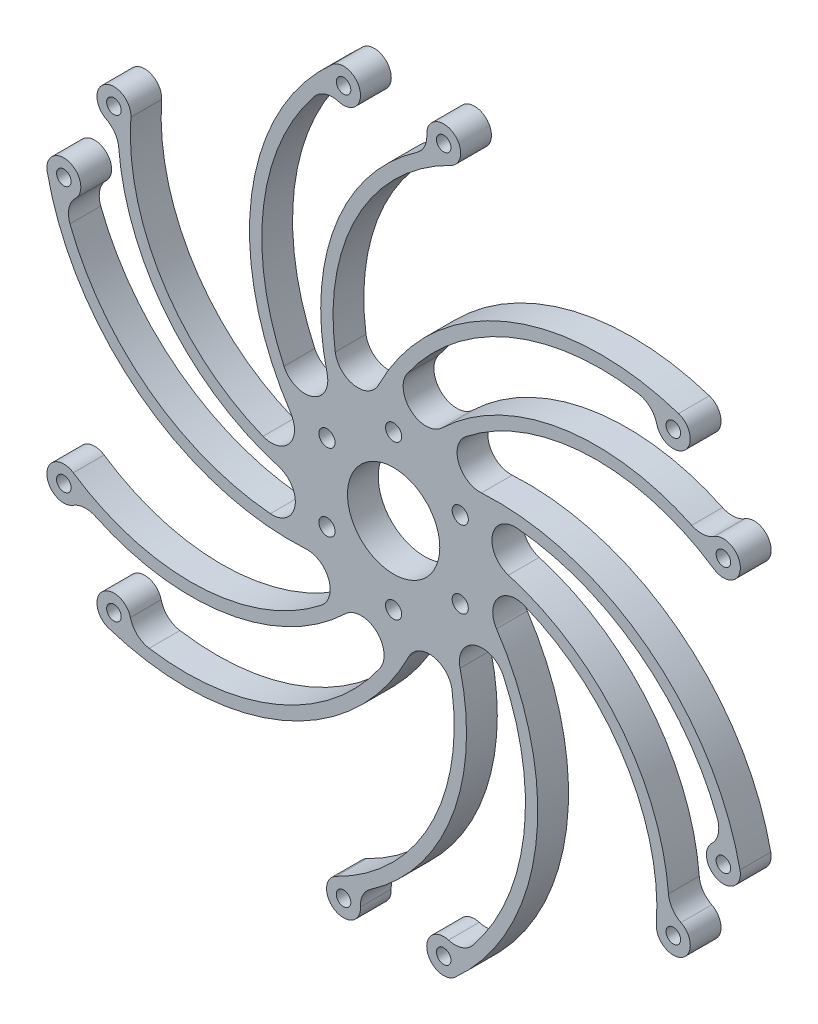
from build123d import *

# Parameters (mm, degrees)
SKETCH1_R                       = 31.75
SKETCH1_R_2                     = 14.2875
BOSS_EXTRUDE1_DEPTH             = 4.7625
BOSS_EXTRUDE2_REACH             = 47.153
SKETCH1_3_R                     = 2.25
BOSS_EXTRUDE2_DIRECTION_2_REACH = 47.153
SKETCH1_5_R                     = 2.5
CUT_EXTRUDE1_DEPTH              = 123.652767423
CIRPATTERN1_COUNT               = 6


with BuildPart() as part:
    # Sketch1 → Boss-Extrude1 (new, symmetric)
    with BuildSketch(Plane.XY):
        Circle(SKETCH1_R)
        Circle(SKETCH1_R_2, mode=Mode.SUBTRACT)
    extrude(amount=BOSS_EXTRUDE1_DEPTH, both=True)

    # Boss-Extrude2: up to this face of the body (flat: up to its plane)
    boss_extrude2_end = Plane(part.part.faces().sort_by_distance((-30.851974388, 0, 4.7625))[0])
    # Sketch1_3 → Boss-Extrude2 (add, up to the picked face)
    with BuildSketch(Plane.XY, mode=Mode.PRIVATE) as boss_extrude2_sk1:
        with BuildLine():
            ThreePointArc((-16.975976856, 103.864226407), (-10.380000805, 110.063559945), (-19.004913728, 112.811197739))
            ThreePointArc((-19.004913728, 112.811197739), (-43.981596647, 65.290659685), (-31.853644116, 12.993919882))
            ThreePointArc((-31.853644116, 12.993919882), (-30.783267014, 10.305575859), (-30.872393941, 7.4133523))
            ThreePointArc((-30.872393941, 7.4133523), (-27.701380897, 15.51438031), (-22.45064034, 22.450640265))
            ThreePointArc((-22.45064034, 22.450640265), (-28.712576811, 20.475279906), (-33.923533352, 24.470255355))
            ThreePointArc((-33.923533352, 24.470255355), (-40.260809011, 64.341772494), (-24.504598742, 101.512201327))
            ThreePointArc((-24.504598742, 101.512201327), (-21.096215477, 103.827506526), (-16.975976856, 103.864226407))
        make_face()
        with Locations((-15.5, 108.902479311)):
            Circle(SKETCH1_3_R, mode=Mode.SUBTRACT)
    boss_extrude2_tool1 = split(extrude(boss_extrude2_sk1.sketch, amount=BOSS_EXTRUDE2_REACH, mode=Mode.PRIVATE), bisect_by=boss_extrude2_end, keep=Keep.BOTH, mode=Mode.PRIVATE)
    # Sketch1_3 → Boss-Extrude2 (add, up to the picked face)
    with BuildSketch(Plane.XY, mode=Mode.PRIVATE) as boss_extrude2_sk2:
        with BuildLine():
            ThreePointArc((-20.572826284, 29.17582828), (-20.629600002, 25.566924084), (-22.45064034, 22.450640265))
            ThreePointArc((-22.45064034, 22.450640265), (-16.232909422, 27.286537921), (-9.016045552, 30.442953579))
            ThreePointArc((-9.016045552, 30.442953579), (-14.868295469, 31.271240847), (-18.073412893, 36.237337019))
            ThreePointArc((-18.073412893, 36.237337019), (-11.212505299, 76.061130888), (17.805097778, 104.185592177))
            ThreePointArc((17.805097778, 104.185592177), (18.158136201, 113.429819804), (10.257775708, 108.616849345))
            ThreePointArc((10.257775708, 108.616849345), (9.542205751, 105.099281948), (7.199837842, 102.379239056))
            ThreePointArc((7.199837842, 102.379239056), (-18.077740957, 70.099262208), (-20.572826284, 29.17582828))
        make_face()
        with Locations((15.5, 108.902479311)):
            Circle(SKETCH1_3_R, mode=Mode.SUBTRACT)
    boss_extrude2_tool2 = split(extrude(boss_extrude2_sk2.sketch, amount=BOSS_EXTRUDE2_REACH, mode=Mode.PRIVATE), bisect_by=boss_extrude2_end, keep=Keep.BOTH, mode=Mode.PRIVATE)
    boss_extrude2_1 = boss_extrude2_tool1.solids().sort_by(Axis((-21.430596, 104.897828, 0), (0, 0, 1)))[0]
    add(boss_extrude2_1)
    boss_extrude2_2 = boss_extrude2_tool2.solids().sort_by(Axis((-19.652799, 25.294181, 0), (0, 0, 1)))[0]
    add(boss_extrude2_2)
    boss_extrude2 = boss_extrude2_1 + boss_extrude2_2  # Boss-Extrude2 as one shape, for the pattern or mirror that repeats it

    # Boss-Extrude2 direction 2: up to this face of the body (flat: up to its plane)
    boss_extrude2_direction_2_end = Plane(part.part.faces().sort_by_distance((-30.851974388, 0, -4.7625))[0])
    # Sketch1_3 → Boss-Extrude2 direction 2 (add, up to the picked face)
    with BuildSketch(Plane.XY, mode=Mode.PRIVATE) as boss_extrude2_direction_2_sk1:
        with BuildLine():
            ThreePointArc((-16.975976856, 103.864226407), (-10.380000805, 110.063559945), (-19.004913728, 112.811197739))
            ThreePointArc((-19.004913728, 112.811197739), (-43.981596647, 65.290659685), (-31.853644116, 12.993919882))
            ThreePointArc((-31.853644116, 12.993919882), (-30.783267014, 10.305575859), (-30.872393941, 7.4133523))
            ThreePointArc((-30.872393941, 7.4133523), (-27.701380897, 15.51438031), (-22.45064034, 22.450640265))
            ThreePointArc((-22.45064034, 22.450640265), (-28.712576811, 20.475279906), (-33.923533352, 24.470255355))
            ThreePointArc((-33.923533352, 24.470255355), (-40.260809011, 64.341772494), (-24.504598742, 101.512201327))
            ThreePointArc((-24.504598742, 101.512201327), (-21.096215477, 103.827506526), (-16.975976856, 103.864226407))
        make_face()
        with Locations((-15.5, 108.902479311)):
            Circle(SKETCH1_3_R, mode=Mode.SUBTRACT)
    boss_extrude2_direction_2_tool1 = split(extrude(boss_extrude2_direction_2_sk1.sketch, amount=-BOSS_EXTRUDE2_DIRECTION_2_REACH, mode=Mode.PRIVATE), bisect_by=boss_extrude2_direction_2_end, keep=Keep.BOTH, mode=Mode.PRIVATE)
    # Sketch1_3 → Boss-Extrude2 direction 2 (add, up to the picked face)
    with BuildSketch(Plane.XY, mode=Mode.PRIVATE) as boss_extrude2_direction_2_sk2:
        with BuildLine():
            ThreePointArc((-20.572826284, 29.17582828), (-20.629600002, 25.566924084), (-22.45064034, 22.450640265))
            ThreePointArc((-22.45064034, 22.450640265), (-16.232909422, 27.286537921), (-9.016045552, 30.442953579))
            ThreePointArc((-9.016045552, 30.442953579), (-14.868295469, 31.271240847), (-18.073412893, 36.237337019))
            ThreePointArc((-18.073412893, 36.237337019), (-11.212505299, 76.061130888), (17.805097778, 104.185592177))
            ThreePointArc((17.805097778, 104.185592177), (18.158136201, 113.429819804), (10.257775708, 108.616849345))
            ThreePointArc((10.257775708, 108.616849345), (9.542205751, 105.099281948), (7.199837842, 102.379239056))
            ThreePointArc((7.199837842, 102.379239056), (-18.077740957, 70.099262208), (-20.572826284, 29.17582828))
        make_face()
        with Locations((15.5, 108.902479311)):
            Circle(SKETCH1_3_R, mode=Mode.SUBTRACT)
    boss_extrude2_direction_2_tool2 = split(extrude(boss_extrude2_direction_2_sk2.sketch, amount=-BOSS_EXTRUDE2_DIRECTION_2_REACH, mode=Mode.PRIVATE), bisect_by=boss_extrude2_direction_2_end, keep=Keep.BOTH, mode=Mode.PRIVATE)
    boss_extrude2_direction_2_1 = boss_extrude2_direction_2_tool1.solids().sort_by(Axis((-21.430596, 104.897828, 0), (0, 0, -1)))[0]
    add(boss_extrude2_direction_2_1)
    boss_extrude2_direction_2_2 = boss_extrude2_direction_2_tool2.solids().sort_by(Axis((-19.652799, 25.294181, 0), (0, 0, -1)))[0]
    add(boss_extrude2_direction_2_2)
    boss_extrude2_direction_2 = boss_extrude2_direction_2_1 + boss_extrude2_direction_2_2  # Boss-Extrude2 direction 2 as one shape, for the pattern or mirror that repeats it

    # Sketch1_5 → Cut-Extrude1 (cut, symmetric)
    with BuildSketch(Plane.XY):
        with Locations((-20.622229928, 11.90625)):
            Circle(SKETCH1_5_R)
    cut_extrude1 = extrude(amount=CUT_EXTRUDE1_DEPTH, both=True, mode=Mode.SUBTRACT)

    # CirPattern1: Boss-Extrude2, Boss-Extrude2 direction 2, Cut-Extrude1 ×6 about axis
    cirpattern1_axis = Axis((0, 0, 4.7625), (0, 0, -1))
    add([boss_extrude2.rotate(cirpattern1_axis, i * 360 / CIRPATTERN1_COUNT) for i in range(1, CIRPATTERN1_COUNT)])
    add([boss_extrude2_direction_2.rotate(cirpattern1_axis, i * 360 / CIRPATTERN1_COUNT) for i in range(1, CIRPATTERN1_COUNT)])
    add([cut_extrude1.rotate(cirpattern1_axis, i * 360 / CIRPATTERN1_COUNT) for i in range(1, CIRPATTERN1_COUNT)], mode=Mode.SUBTRACT)


solid = part.part
